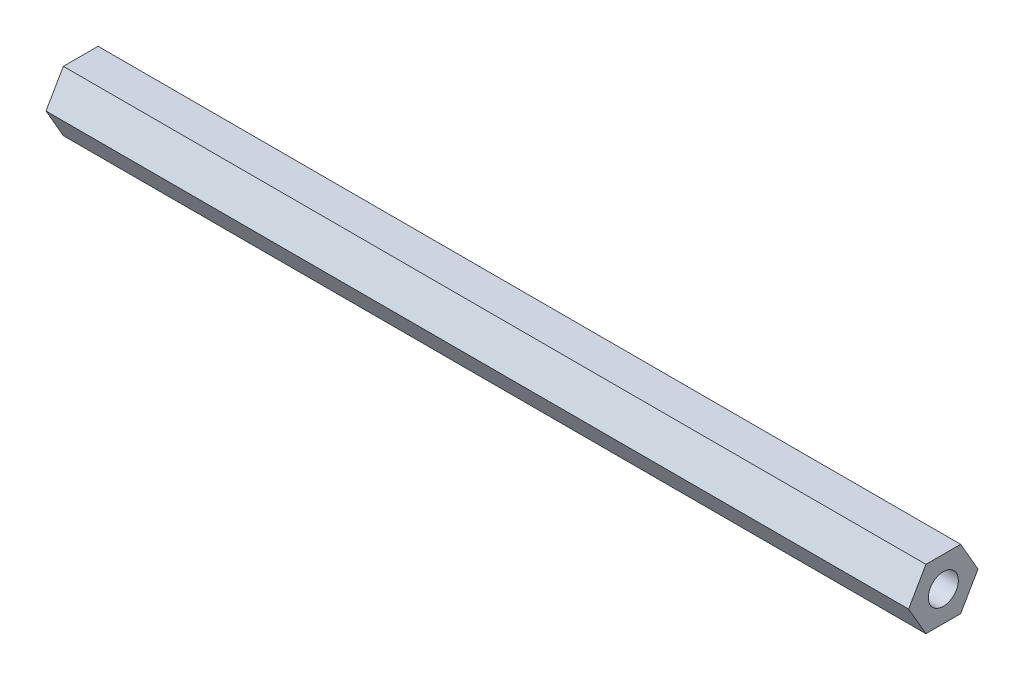
from build123d import *

# Parameters (mm, degrees)
BOSS_EXTRUDE1_DEPTH       = 71.755
M3X0_5_TAPPED_HOLE1_D     = 2.5
M3X0_5_TAPPED_HOLE1_DEPTH = 7.493
M3X0_5_TAPPED_HOLE1_TIP   = 0.751075774
M3X0_5_TAPPED_HOLE2_D     = 2.5
M3X0_5_TAPPED_HOLE2_DEPTH = 7.493
M3X0_5_TAPPED_HOLE2_TIP   = 0.751075774


with BuildPart() as part:
    # Sketch1 → Boss-Extrude1 (new body)
    with BuildSketch(Plane(origin=(0, 0, 0), x_dir=(0, 0, -1), z_dir=(1, 0, 0))):
        Polygon((1.443375673, 2.5), (-1.443375673, 2.5), (-2.886751346, 0), (-1.443375673, -2.5), (1.443375673, -2.5), (2.886751346, 0), align=None)
    extrude(amount=BOSS_EXTRUDE1_DEPTH)

    # M3x0.5 Tapped Hole1
    with Locations(Plane.ZY):
        with Locations((0, 0)):
            Hole(M3X0_5_TAPPED_HOLE1_D / 2, depth=M3X0_5_TAPPED_HOLE1_DEPTH)
            with Locations((0, 0, -(M3X0_5_TAPPED_HOLE1_DEPTH + M3X0_5_TAPPED_HOLE1_TIP / 2))):  # 118° drill point
                Cone(0, M3X0_5_TAPPED_HOLE1_D / 2, M3X0_5_TAPPED_HOLE1_TIP, mode=Mode.SUBTRACT)

    # M3x0.5 Tapped Hole2
    with Locations(Plane(origin=(71.755, 0, 0), x_dir=(0, 0, -1), z_dir=(1, 0, 0))):
        with Locations((0, 0)):
            Hole(M3X0_5_TAPPED_HOLE2_D / 2, depth=M3X0_5_TAPPED_HOLE2_DEPTH)
            with Locations((0, 0, -(M3X0_5_TAPPED_HOLE2_DEPTH + M3X0_5_TAPPED_HOLE2_TIP / 2))):  # 118° drill point
                Cone(0, M3X0_5_TAPPED_HOLE2_D / 2, M3X0_5_TAPPED_HOLE2_TIP, mode=Mode.SUBTRACT)


solid = part.part
